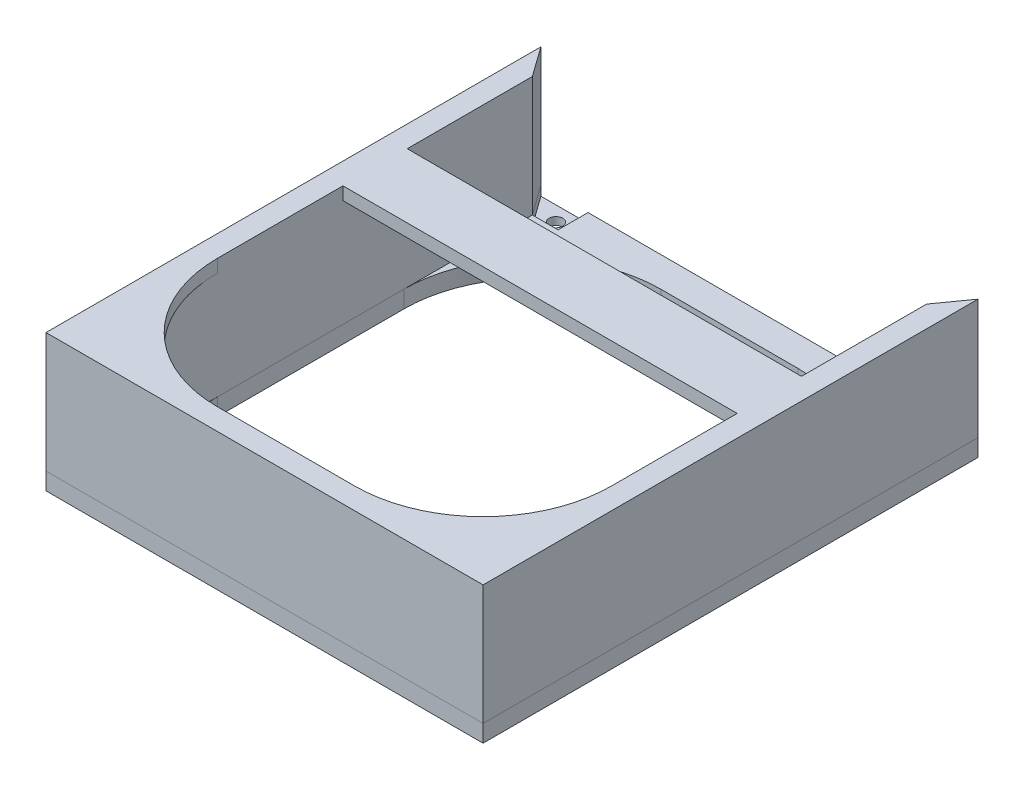
from build123d import *

# Parameters (mm, degrees)
SKETCH1_R           = 1.6
BOSS_EXTRUDE2_DEPTH = 4
BOSS_EXTRUDE3_DEPTH = 25
CUT_EXTRUDE1_DEPTH  = 2.2
BOSS_EXTRUDE4_DEPTH = 3


with BuildPart() as part:
    # Sketch1 → Boss-Extrude2 (new body)
    with BuildSketch(Plane(origin=(0, 0, 0), x_dir=(1, 0, 0), z_dir=(0, 1, 0))):
        Polygon((-44, 52.958818287), (-51, 52.958818287), (-51, -62.541181713), (51, -62.541181713), (51, 52.958818287), (44, 52.958818287), align=None)
        with BuildLine():
            ThreePointArc((46, -27.541181713), (37.213203436, -48.754385149), (16, -57.541181713))
            Line((16, -57.541181713), (-16, -57.541181713))
            ThreePointArc((-16, -57.541181713), (-37.213203436, -48.754385149), (-46, -27.541181713))
            Line((-46, -27.541181713), (-46, 15.958818287))
            ThreePointArc((-46, 15.958818287), (-37.213203436, 37.172021722), (-16, 45.958818287))
            Line((-16, 45.958818287), (16, 45.958818287))
            ThreePointArc((16, 45.958818287), (37.213203436, 37.172021722), (46, 15.958818287))
            Line((46, 15.958818287), (46, -27.541181713))
        make_face(mode=Mode.SUBTRACT)
        with Locations((-44, 49.458818287)):
            Circle(SKETCH1_R, mode=Mode.SUBTRACT)
        with Locations((44, 49.458818287)):
            Circle(SKETCH1_R, mode=Mode.SUBTRACT)
    extrude(amount=BOSS_EXTRUDE2_DEPTH)

    # Sketch3 → Cut-Extrude1 (cut)
    with BuildSketch(Plane(origin=(0, 4, 0), x_dir=(1, 0, 0), z_dir=(0, 1, 0))):
        Polygon((-51, 52.958818287), (-40, 52.958818287), (-40, 45.958818287), (-46, 45.958818287), align=None)
        Polygon((40, 45.958818287), (46, 45.958818287), (51, 52.958818287), (40, 52.958818287), align=None)
    extrude(amount=-CUT_EXTRUDE1_DEPTH, mode=Mode.SUBTRACT)


with BuildPart() as body_2:
    # Sketch2 → Boss-Extrude3 (new body)
    with BuildSketch(Plane(origin=(0, 4, 0), x_dir=(1, 0, 0), z_dir=(0, 1, 0))):
        Polygon((-51, -62.541181713), (51, -62.541181713), (51, 52.958818287), (46, 45.958818287), (46, -57.541181713), (-46, -57.541181713), (-46, 45.958818287), (-51, 52.958818287), align=None)
    extrude(amount=BOSS_EXTRUDE3_DEPTH)

    # Sketch4 → Boss-Extrude4 (add)
    with BuildSketch(Plane(origin=(0, 29, 0), x_dir=(1, 0, 0), z_dir=(0, 1, 0))):
        Polygon((-46, 45.958818287), (-51, 52.958818287), (-51, -62.541181713), (51, -62.541181713), (51, 52.958818287), (46, 45.958818287), (46, 16.759345997), (-46, 16.759345997), align=None)
        with BuildLine():
            Line((-46, -27.541181713), (-46, 1.759345997))
            Line((-46, 1.759345997), (46, 1.759345997))
            Line((46, 1.759345997), (46, -27.541181713))
            ThreePointArc((46, -27.541181713), (37.213203436, -48.754385149), (16, -57.541181713))
            Line((16, -57.541181713), (-16, -57.541181713))
            ThreePointArc((-16, -57.541181713), (-37.213203436, -48.754385149), (-46, -27.541181713))
        make_face(mode=Mode.SUBTRACT)
    extrude(amount=BOSS_EXTRUDE4_DEPTH)


solid = Compound([part.part, body_2.part])
